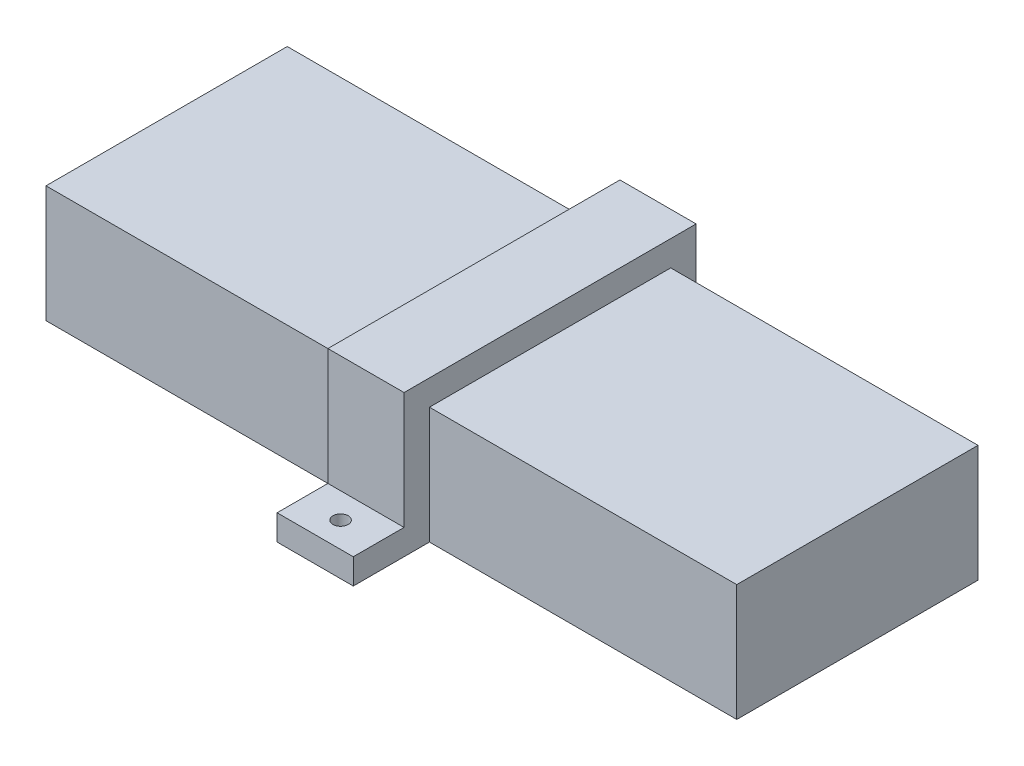
from build123d import *

# Parameters (mm, degrees)
SKETCH1_W           = 136
SKETCH1_H           = 47.5
BOSS_EXTRUDE1_DEPTH = 23
BOSS_EXTRUDE2_DEPTH = 7.5
SKETCH6_R           = 1.5
CUT_EXTRUDE1_DEPTH  = 10


with BuildPart() as part:
    # Sketch1 → Boss-Extrude1 (new body)
    with BuildSketch(Plane(origin=(0, 0, 0), x_dir=(1, 0, 0), z_dir=(0, 1, 0))):
        Rectangle(SKETCH1_W, SKETCH1_H)
    extrude(amount=BOSS_EXTRUDE1_DEPTH)


with BuildPart() as body_2:
    # Sketch5 → Boss-Extrude2 (new body, symmetric)
    with BuildSketch(Plane(origin=(0, 0, 0), x_dir=(0, 0, -1), z_dir=(1, 0, 0))):
        Polygon((-38.75, 5), (-38.75, 0), (-23.75, 0), (-23.75, 23), (23.75, 23), (23.75, 0), (38.75, 0), (38.75, 5), (28.75, 5), (28.75, 28), (-28.75, 28), (-28.75, 5), align=None)
    extrude(amount=BOSS_EXTRUDE2_DEPTH, both=True)

    # Sketch6 → Cut-Extrude1 (cut)
    with BuildSketch(Plane(origin=(0, 0, 0), x_dir=(1, 0, 0), z_dir=(0, 1, 0))):
        with Locations((0, 33.75)):
            Circle(SKETCH6_R)
        with Locations((0, -33.75)):
            Circle(SKETCH6_R)
    extrude(amount=CUT_EXTRUDE1_DEPTH, mode=Mode.SUBTRACT)


solid = Compound([part.part, body_2.part])
